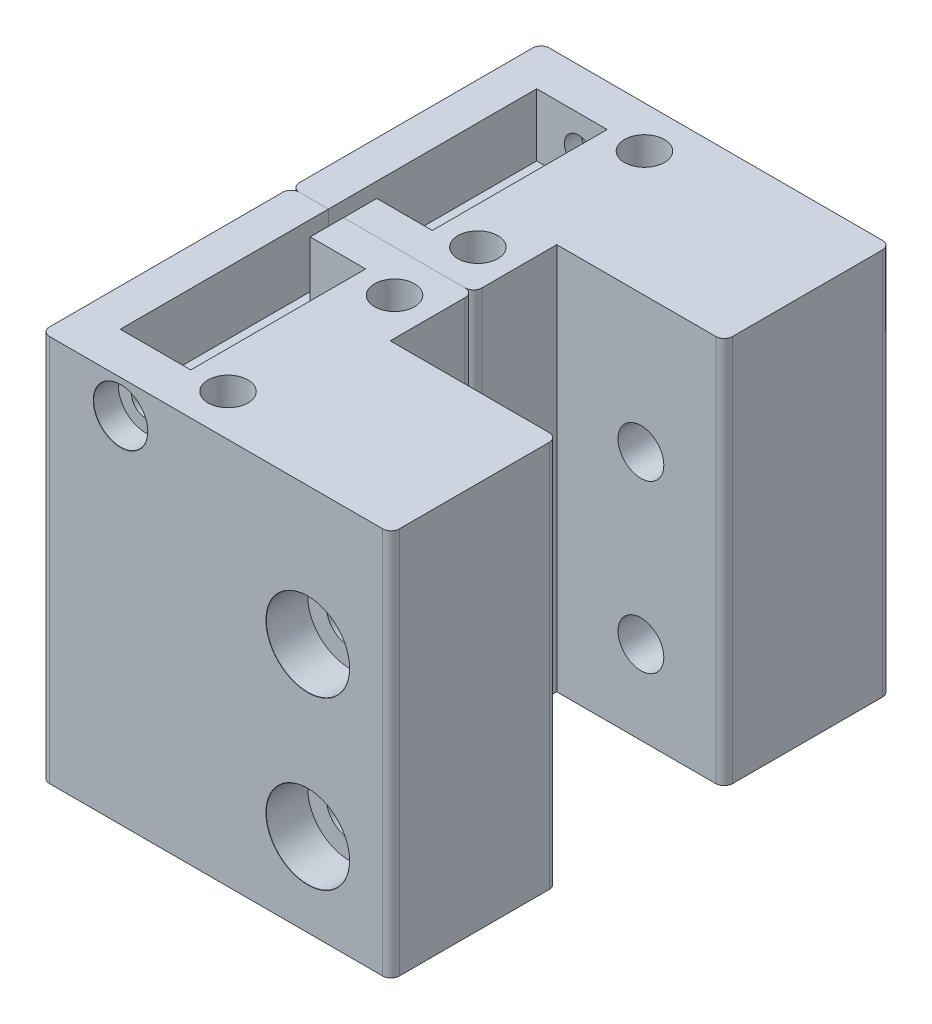
from build123d import *

# Parameters (mm, degrees)
SKETCH1_W                     = 42
SKETCH1_H                     = 20
BOSS_EXTRUDE1_DEPTH           = 40
CBORE_FOR_M5_SHCS1_AT_2_COUNT = 2
CBORE_FOR_M5_SHCS1_AT_2_PITCH = 20
SKETCH5_W                     = 42
SKETCH5_H                     = 20
BOSS_EXTRUDE2_DEPTH           = 6.5
SKETCH12_W                    = 21.9
SKETCH12_H                    = 10
BOSS_EXTRUDE3_DEPTH           = 46.5
CUT_EXTRUDE1_DEPTH            = 7.5
FILLET1_R                     = 1
SKETCH14_R                    = 2.4
CUT_EXTRUDE2_DEPTH            = 3.8
SKETCH15_R                    = 1.7
CUT_EXTRUDE3_DEPTH            = 3


with BuildPart() as part:
    # Sketch1 → Boss-Extrude1 (new body)
    with BuildSketch(Plane(origin=(0, 0, 0), x_dir=(1, 0, 0), z_dir=(0, 1, 0))):
        Rectangle(SKETCH1_W, SKETCH1_H)
    extrude(amount=BOSS_EXTRUDE1_DEPTH)

    # Sketch4 → CBORE for M5 SHCS1 (revolve, cut)
    with BuildSketch(Plane(origin=(11, 30, 10), x_dir=(0, -1, 0), z_dir=(1, 0, 0))):
        Polygon((0, 0), (0, 20), (2.75, 20), (2.75, 5), (5, 5), (5, 0.020977491), (5.025, 0), align=None)
    cbore_for_m5_shcs1 = revolve(axis=Axis((11, 30, 16.35), (0, 0, -1)), mode=Mode.SUBTRACT)

    # CBORE for M5 SHCS1 at 2: CBORE for M5 SHCS1 ×2
    with Locations(*[(0, -i * CBORE_FOR_M5_SHCS1_AT_2_PITCH, 0) for i in range(1, CBORE_FOR_M5_SHCS1_AT_2_COUNT)]):
        add(cbore_for_m5_shcs1, mode=Mode.SUBTRACT)

    # Sketch5 → Boss-Extrude2 (add)
    with BuildSketch(Plane(origin=(0, 40, 0), x_dir=(1, 0, 0), z_dir=(0, 1, 0))):
        Rectangle(SKETCH5_W, SKETCH5_H)
    extrude(amount=BOSS_EXTRUDE2_DEPTH)

    # Sketch12 → Boss-Extrude3 (add)
    with BuildSketch(Plane(origin=(0, 46.5, 0), x_dir=(1, 0, 0), z_dir=(0, 1, 0))):
        with Locations((-10.05, 15)):
            Rectangle(SKETCH12_W, SKETCH12_H)
    extrude(amount=-BOSS_EXTRUDE3_DEPTH)

    # Sketch6 → Cut-Extrude1 (cut)
    with BuildSketch(Plane(origin=(0, 46.5, 0), x_dir=(1, 0, 0), z_dir=(0, 1, 0))):
        Polygon((-16.51, 20), (-16.51, -5), (-8.05, -5), (-8.05, 16), (-14.71, 16), (-14.71, 20), align=None)
    extrude(amount=-CUT_EXTRUDE1_DEPTH, mode=Mode.SUBTRACT)

    # Fillet1
    fillet1_edges = [part.edges().sort_by_distance(p)[0] for p in [
        (0.9, 23.25, -20),
        (-21, 23.25, -20),
        (21, 23.25, -10),
        (21, 23.25, 10),
        (-21, 23.25, 10),
    ]]
    fillet(fillet1_edges, radius=FILLET1_R)

    # Sketch11 → CBORE for M3 SHCS1 (revolve, cut)
    with BuildSketch(Plane(origin=(-11.48, 42.5, 10), x_dir=(0, -1, 0), z_dir=(1, 0, 0))):
        Polygon((0, 0), (0, 6.021463052), (1.7, 5), (1.7, 3), (3.25, 3), (3.25, 0.020977491), (3.275, 0), align=None)
    revolve(axis=Axis((-11.48, 42.5, 16.35), (0, 0, -1)), mode=Mode.SUBTRACT)

    # Sketch14 → Cut-Extrude2 (cut)
    with BuildSketch(Plane(origin=(0, 46.5, 0), x_dir=(1, 0, 0), z_dir=(0, 1, 0))):
        with Locations((-3.575, 15)):
            Circle(SKETCH14_R)
        with Locations((-3.575, -5)):
            Circle(SKETCH14_R)
    extrude(amount=-CUT_EXTRUDE2_DEPTH, mode=Mode.SUBTRACT)

    # Sketch15 → Cut-Extrude3 (cut)
    with BuildSketch(Plane(origin=(0, 42.7, 0), x_dir=(1, 0, 0), z_dir=(0, 1, 0))):
        with Locations((-3.575, 15)):
            Circle(SKETCH15_R)
        with Locations((-3.575, -5)):
            Circle(SKETCH15_R)
    extrude(amount=-CUT_EXTRUDE3_DEPTH, mode=Mode.SUBTRACT)


with BuildPart() as body_2:
    # Mirror1: mirrored copy
    add(part.part.mirror(Plane(origin=(-21, -24.075090862, -20), x_dir=(1, 0, 0), z_dir=(0, 0, -1))))


solid = Compound([part.part, body_2.part])
